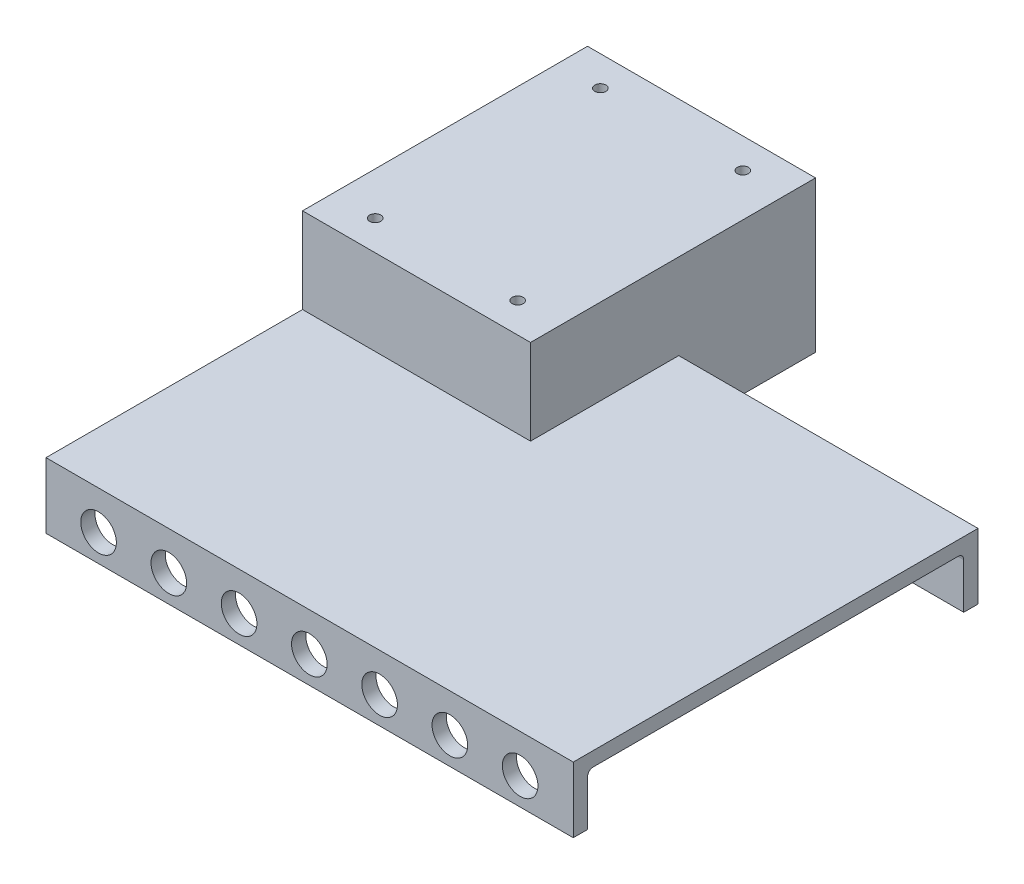
from build123d import *

# Parameters (mm, degrees)
SKETCH1_W           = 185
SKETCH1_H           = 142
BOSS_EXTRUDE1_DEPTH = 23
SKETCH12_W          = 80
SKETCH12_H          = 100
BOSS_EXTRUDE6_DEPTH = 53
SHELL1_T            = -5
SKETCH11_R          = 6.25
CUT_EXTRUDE2_DEPTH  = 6
FILLET1_R           = 2
SKETCH13_R          = 1.95
CUT_EXTRUDE3_DEPTH  = 54


with BuildPart() as part:
    # Sketch1 → Boss-Extrude1 (new body)
    with BuildSketch(Plane(origin=(0, 0, 0), x_dir=(1, 0, 0), z_dir=(0, 1, 0))):
        with Locations((92.5, 71)):
            Rectangle(SKETCH1_W, SKETCH1_H)
    extrude(amount=BOSS_EXTRUDE1_DEPTH)

    # Sketch12 → Boss-Extrude6 (add)
    with BuildSketch(Plane(origin=(0, 0, 0), x_dir=(1, 0, 0), z_dir=(0, 1, 0))):
        with Locations((40, 140)):
            Rectangle(SKETCH12_W, SKETCH12_H)
    extrude(amount=BOSS_EXTRUDE6_DEPTH)

    # Shell1
    shell1_openings = [part.faces().sort_by_distance(p)[0] for p in [
        (88.333333333, 0, -110.666666667),
        (185, 11.5, -71),
        (0, 25.333333333, -93.333333333),
    ]]
    offset(amount=SHELL1_T, openings=shell1_openings, kind=Kind.INTERSECTION)

    # Sketch11 → Cut-Extrude2 (cut)
    with BuildSketch(Plane.XY):
        with Locations((18.4375, 9.5)):
            Circle(SKETCH11_R)
        with Locations((43.088852194, 9.5)):
            Circle(SKETCH11_R)
        with Locations((67.740204388, 9.5)):
            Circle(SKETCH11_R)
        with Locations((92.391556582, 9.5)):
            Circle(SKETCH11_R)
        with Locations((117.042908776, 9.5)):
            Circle(SKETCH11_R)
        with Locations((141.69426097, 9.5)):
            Circle(SKETCH11_R)
        with Locations((166.345613164, 9.5)):
            Circle(SKETCH11_R)
    extrude(amount=-CUT_EXTRUDE2_DEPTH, mode=Mode.SUBTRACT)

    # Fillet1
    fillet1_edges = [part.edges().sort_by_distance(p)[0] for p in [
        (92.5, 18, -5),
        (130, 18, -137),
        (37.5, 48, -95),
        (75, 48, -140),
        (37.5, 48, -185),
    ]]
    fillet(fillet1_edges, radius=FILLET1_R)

    # Sketch13 → Cut-Extrude3 (cut, through all)
    with BuildSketch(Plane(origin=(0, 53, 0), x_dir=(1, 0, 0), z_dir=(0, 1, 0))):
        with Locations((15, 100.5)):
            Circle(SKETCH13_R)
        with Locations((15, 179.5)):
            Circle(SKETCH13_R)
        with Locations((65, 179.5)):
            Circle(SKETCH13_R)
        with Locations((65, 100.5)):
            Circle(SKETCH13_R)
    extrude(amount=-CUT_EXTRUDE3_DEPTH, mode=Mode.SUBTRACT)


solid = part.part
